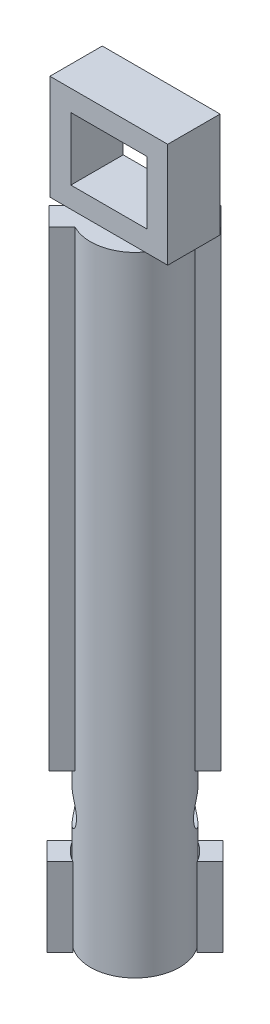
from build123d import *

# Parameters (mm, degrees)
SKETCH1_R             = 1.7
MAIN_BODY_DEPTH       = 12
TOP_GUIDES_DEPTH      = 18
BOTTOM_GUIDES_DEPTH   = 3
BOTTOM_GUIDES_2_DEPTH = 3
SKETCH10_W            = 4.5
SKETCH10_H            = 2
HOLE_EXTRUDE_DEPTH    = 4
SKETCH11_W            = 2.9
SKETCH11_H            = 2.4
HOLE_CUT_DEPTH        = 4.03438226
SKETCH12_W            = 0.625
SKETCH12_H            = 5.328201779


with BuildPart() as part:
    # Sketch1 → main body (new body, symmetric)
    with BuildSketch(Plane(origin=(0, 0, 0), x_dir=(1, 0, 0), z_dir=(0, 1, 0))):
        Circle(SKETCH1_R)
    extrude(amount=MAIN_BODY_DEPTH, both=True)

    # Sketch2 → top guides (add)
    with BuildSketch(Plane(origin=(0, 12, 0), x_dir=(1, 0, 0), z_dir=(0, 1, 0))):
        with BuildLine():
            Line((-0.795359139, -1.50246592), (-1.290333886, -1.997440667))
            Line((-1.290333886, -1.997440667), (-1.997440667, -1.290333886))
            Line((-1.997440667, -1.290333886), (-1.50246592, -0.795359139))
            ThreePointArc((-1.50246592, -0.795359139), (-1.202081528, -1.202081528), (-0.795359139, -1.50246592))
        make_face()
        with BuildLine():
            Line((1.290333886, 1.997440667), (0.795359139, 1.50246592))
            ThreePointArc((0.795359139, 1.50246592), (1.202081528, 1.202081528), (1.50246592, 0.795359139))
            Line((1.50246592, 0.795359139), (1.997440667, 1.290333886))
            Line((1.997440667, 1.290333886), (1.290333886, 1.997440667))
        make_face()
    extrude(amount=-TOP_GUIDES_DEPTH)

    # Sketch10 → hole extrude (add)
    with BuildSketch(Plane(origin=(0, 12, 0), x_dir=(1, 0, 0), z_dir=(0, 1, 0))):
        Rectangle(SKETCH10_W, SKETCH10_H)
    extrude(amount=HOLE_EXTRUDE_DEPTH)

    # Sketch11 → hole cut (cut, through all)
    with BuildSketch(Plane.XY.offset(-1)):
        with Locations((0, 14)):
            Rectangle(SKETCH11_W, SKETCH11_H)
    extrude(amount=HOLE_CUT_DEPTH, mode=Mode.SUBTRACT)

    # Sketch12 → M1.6 Tapped Hole4 (revolve, cut)
    with BuildSketch(Plane(origin=(-1.643887276, -7.5, 1.643887276), x_dir=(0.707106781, 0, 0.707106781), z_dir=(0, 1, 0))):
        with Locations((0.3125, 2.66410089)):
            Rectangle(SKETCH12_W, SKETCH12_H)
    revolve(axis=Axis((-6.134015337, -7.5, 6.134015337), (0.707106781, 0, -0.707106781)), mode=Mode.SUBTRACT)


with BuildPart() as body_2:
    # Sketch7 → bottom guides (new body)
    with BuildSketch(Plane.XZ.offset(12)):
        with BuildLine():
            Line((1.539407513, -0.832300732), (2.03438226, -1.327275479))
            Line((2.03438226, -1.327275479), (1.327275479, -2.03438226))
            Line((1.327275479, -2.03438226), (0.832300732, -1.539407513))
            ThreePointArc((0.832300732, -1.539407513), (1.237436867, -1.237436867), (1.539407513, -0.832300732))
        make_face()
    extrude(amount=-BOTTOM_GUIDES_DEPTH)


with BuildPart() as body_3:
    # Sketch7 → bottom guides 2 (new body)
    with BuildSketch(Plane.XZ.offset(12)):
        with BuildLine():
            Line((-2.03438226, 1.327275479), (-1.539407513, 0.832300732))
            ThreePointArc((-1.539407513, 0.832300732), (-1.237436867, 1.237436867), (-0.832300732, 1.539407513))
            Line((-0.832300732, 1.539407513), (-1.327275479, 2.03438226))
            Line((-1.327275479, 2.03438226), (-2.03438226, 1.327275479))
        make_face()
    extrude(amount=-BOTTOM_GUIDES_2_DEPTH)


solid = Compound([part.part, body_2.part, body_3.part])
